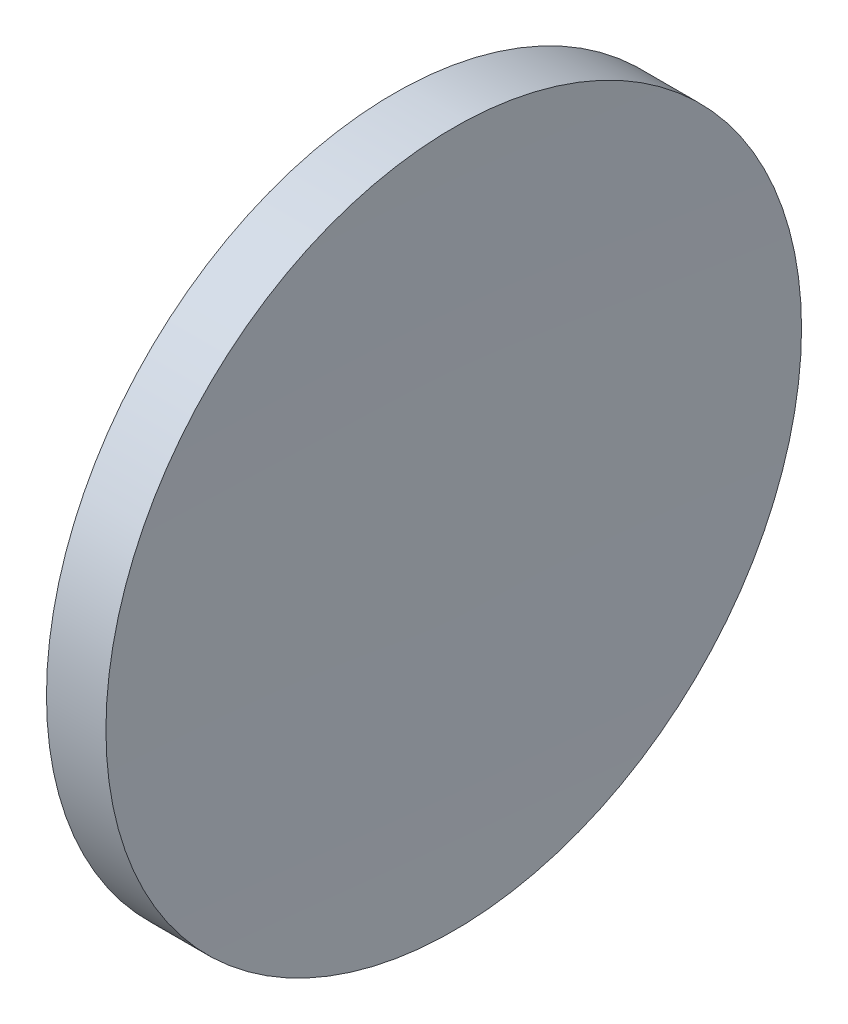
from build123d import *


with BuildPart() as part:
    # 草图1 → 旋转1 (revolve)
    with BuildSketch(Plane.XY, mode=Mode.PRIVATE) as revolve_1_sk:
        with BuildLine():
            Line((57.532337053, 32.610768129), (57.532337053, 45.110768129))
            Line((57.532337053, 45.110768129), (59.669380626, 45.110768129))
            ThreePointArc((59.669380626, 45.110768129), (59.563040565, 38.861182749), (59.532337053, 32.610768129))
            Line((59.532337053, 32.610768129), (57.532337053, 32.610768129))
        make_face()
    revolve(revolve_1_sk.sketch.rotate(Axis((56.10091508, 32.610768129, 0), (1, 0, 0)), 90), axis=Axis((56.10091508, 32.610768129, 0), (1, 0, 0)))  # turned: the seam where the file's is


solid = part.part
